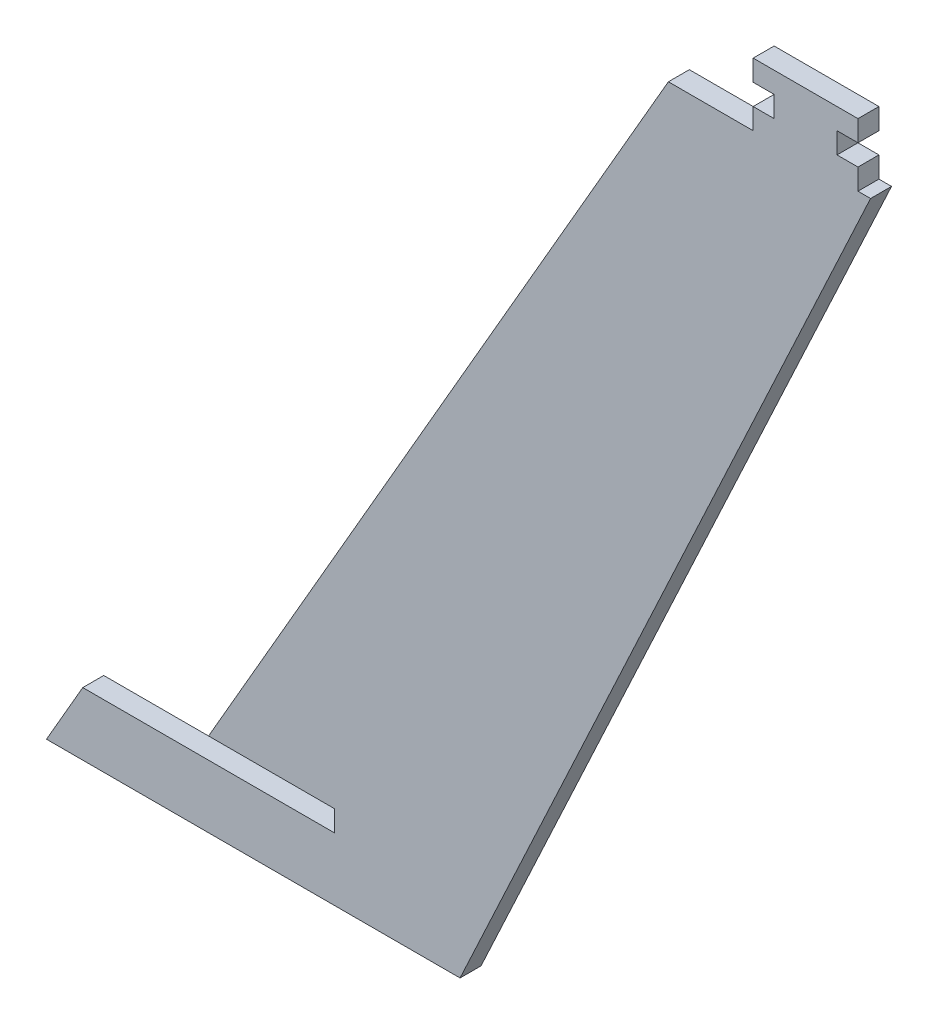
from build123d import *

# Parameters (mm, degrees)
EXTRUDE_1_DEPTH     = 5
CUT_EXTRUDE_1_REACH = 7
SKETCH_2_W          = 19.790240303
SKETCH_2_H          = 15
SKETCH_2_W_2        = 23.6545041
CUT_EXTRUDE_2_REACH = 7
SKETCH_3_W          = 5
SKETCH_3_H          = 5


with BuildPart() as part:
    # 草图1 → 凸台-拉伸1 (new body)
    with BuildSketch(Plane.XY):
        Polygon((0, 0), (-98.660254038, 0), (-90, 15), (-30, 15), (-30, 20), (-60, 20), (58.356805184, 225), (104.919223085, 225), align=None)
    extrude(amount=EXTRUDE_1_DEPTH)

    # 草图2 → 切除-拉伸1 (cut, up to next)
    with BuildSketch(Plane.XY.offset(5), mode=Mode.PRIVATE) as cut_extrude_1_sk1:
        with Locations((104.814343237, 217.5)):
            Rectangle(SKETCH_2_W, SKETCH_2_H)
    cut_extrude_1_tool1 = extrude(cut_extrude_1_sk1.sketch, amount=-CUT_EXTRUDE_1_REACH, mode=Mode.PRIVATE) & part.part
    add(cut_extrude_1_tool1.solids().sort_by_distance((104.814343, 217.5, 5))[0], mode=Mode.SUBTRACT)
    # 草图2 → 切除-拉伸1 (cut, up to next)
    with BuildSketch(Plane.XY.offset(5), mode=Mode.PRIVATE) as cut_extrude_1_sk2:
        with Locations((58.091971035, 217.5)):
            Rectangle(SKETCH_2_W_2, SKETCH_2_H)
    cut_extrude_1_tool2 = extrude(cut_extrude_1_sk2.sketch, amount=-CUT_EXTRUDE_1_REACH, mode=Mode.PRIVATE) & part.part
    add(cut_extrude_1_tool2.solids().sort_by_distance((58.091971, 217.5, 5))[0], mode=Mode.SUBTRACT)

    # 草图3 → 切除-拉伸2 (cut, up to next)
    with BuildSketch(Plane.XY.offset(5), mode=Mode.PRIVATE) as cut_extrude_2_sk1:
        with Locations((72.419223085, 217.5)):
            Rectangle(SKETCH_3_W, SKETCH_3_H)
    cut_extrude_2_tool1 = extrude(cut_extrude_2_sk1.sketch, amount=-CUT_EXTRUDE_2_REACH, mode=Mode.PRIVATE) & part.part
    add(cut_extrude_2_tool1.solids().sort_by_distance((72.419223, 217.5, 5))[0], mode=Mode.SUBTRACT)
    # 草图3 → 切除-拉伸2 (cut, up to next)
    with BuildSketch(Plane.XY.offset(5), mode=Mode.PRIVATE) as cut_extrude_2_sk2:
        with Locations((92.419223085, 217.5)):
            Rectangle(SKETCH_3_W, SKETCH_3_H)
    cut_extrude_2_tool2 = extrude(cut_extrude_2_sk2.sketch, amount=-CUT_EXTRUDE_2_REACH, mode=Mode.PRIVATE) & part.part
    add(cut_extrude_2_tool2.solids().sort_by_distance((92.419223, 217.5, 5))[0], mode=Mode.SUBTRACT)


solid = part.part
